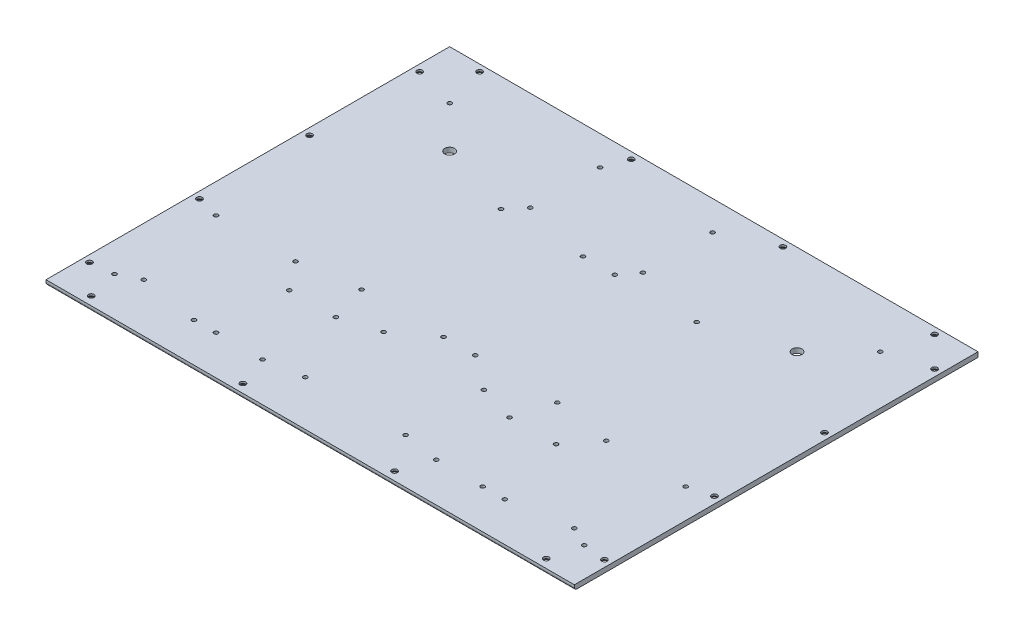
from build123d import *

# Parameters (mm, degrees)
SKETCH_2_W                   = 432
SKETCH_2_H                   = 330
EXTRUDE_1_DEPTH              = 4
HOLE_WIZARD_406_AT_2_COUNT   = 2
HOLE_WIZARD_406_AT_2_PITCH   = 294.02253315
HOLE_WIZARD_406_AT_3_COUNT   = 2
HOLE_WIZARD_406_AT_3_PITCH   = 204.473103366
HOLE_WIZARD_406_AT_4_COUNT   = 2
HOLE_WIZARD_406_AT_4_PITCH   = 115.625472972
HOLE_WIZARD_406_AT_5_COUNT   = 2
HOLE_WIZARD_406_AT_5_PITCH   = 33.604315199
HOLE_WIZARD_406_AT_6_COUNT   = 2
HOLE_WIZARD_406_AT_6_PITCH   = 124
HOLE_WIZARD_406_AT_7_COUNT   = 2
HOLE_WIZARD_406_AT_7_PITCH   = 248
HOLE_WIZARD_406_AT_8_COUNT   = 2
HOLE_WIZARD_406_AT_8_PITCH   = 372
HOLE_WIZARD_406_AT_9_COUNT   = 2
HOLE_WIZARD_406_AT_9_PITCH   = 397.166526787
HOLE_WIZARD_406_AT_10_COUNT  = 2
HOLE_WIZARD_406_AT_10_PITCH  = 412.28782422
HOLE_WIZARD_406_AT_11_COUNT  = 2
HOLE_WIZARD_406_AT_11_PITCH  = 445.445002217
HOLE_WIZARD_406_AT_12_COUNT  = 2
HOLE_WIZARD_406_AT_12_PITCH  = 493.012423779
HOLE_WIZARD_406_AT_13_COUNT  = 2
HOLE_WIZARD_406_AT_13_PITCH  = 489.070802645
HOLE_WIZARD_406_AT_14_COUNT  = 2
HOLE_WIZARD_406_AT_14_PITCH  = 402.87746276
HOLE_WIZARD_406_AT_15_COUNT  = 2
HOLE_WIZARD_406_AT_15_PITCH  = 340.855174524
HOLE_WIZARD_406_AT_16_COUNT  = 2
HOLE_WIZARD_406_AT_16_PITCH  = 317.5
FILLET_1_R                   = 2
HOLE_WIZARD_1584_D           = 8
M4P8_D                       = 3.3
HOLE_WIZARD_3528_D           = 3.3
HOLE_WIZARD_3528_CSINK_D     = 4.05
HOLE_WIZARD_3528_CSINK_ANGLE = 90
M4P9_D                       = 3.3
M4P10_D                      = 3.3


with BuildPart() as part:
    # 草圖2 → 填料-伸長1 (new body)
    with BuildSketch(Plane(origin=(0, 0, 0), x_dir=(1, 0, 0), z_dir=(0, 1, 0))):
        with Locations((216, 165)):
            Rectangle(SKETCH_2_W, SKETCH_2_H)
    extrude(amount=EXTRUDE_1_DEPTH)

    # 草圖3 → Hole Wizard 406 (revolve, cut)
    with BuildSketch(Plane(origin=(30, 0, -7), x_dir=(0, 0, -1), z_dir=(1, 0, 0))):
        Polygon((0, 0), (0, 4), (2.25, 4), (2.25, 2.45), (4.7, 0), align=None)
    hole_wizard_406 = revolve(axis=Axis((30, -6.35, -7), (0, 1, 0)), mode=Mode.SUBTRACT)

    # Hole Wizard 406 at 2: Hole Wizard 406 ×2
    with Locations(*[Vector(-0.083326947, 0, -0.996522263) * (i * HOLE_WIZARD_406_AT_2_PITCH) for i in range(1, HOLE_WIZARD_406_AT_2_COUNT)]):
        add(hole_wizard_406, mode=Mode.SUBTRACT)

    # Hole Wizard 406 at 3: Hole Wizard 406 ×2
    with Locations(*[Vector(-0.11982016, 0, -0.992795613) * (i * HOLE_WIZARD_406_AT_3_PITCH) for i in range(1, HOLE_WIZARD_406_AT_3_COUNT)]):
        add(hole_wizard_406, mode=Mode.SUBTRACT)

    # Hole Wizard 406 at 4: Hole Wizard 406 ×2
    with Locations(*[Vector(-0.211891025, 0, -0.9772933) * (i * HOLE_WIZARD_406_AT_4_PITCH) for i in range(1, HOLE_WIZARD_406_AT_4_COUNT)]):
        add(hole_wizard_406, mode=Mode.SUBTRACT)

    # Hole Wizard 406 at 5: Hole Wizard 406 ×2
    with Locations(*[Vector(-0.729073033, 0, -0.684435908) * (i * HOLE_WIZARD_406_AT_5_PITCH) for i in range(1, HOLE_WIZARD_406_AT_5_COUNT)]):
        add(hole_wizard_406, mode=Mode.SUBTRACT)

    # Hole Wizard 406 at 6: Hole Wizard 406 ×2
    with Locations(*[(i * HOLE_WIZARD_406_AT_6_PITCH, 0, 0) for i in range(1, HOLE_WIZARD_406_AT_6_COUNT)]):
        add(hole_wizard_406, mode=Mode.SUBTRACT)

    # Hole Wizard 406 at 7: Hole Wizard 406 ×2
    with Locations(*[(i * HOLE_WIZARD_406_AT_7_PITCH, 0, 0) for i in range(1, HOLE_WIZARD_406_AT_7_COUNT)]):
        add(hole_wizard_406, mode=Mode.SUBTRACT)

    # Hole Wizard 406 at 8: Hole Wizard 406 ×2
    with Locations(*[(i * HOLE_WIZARD_406_AT_8_PITCH, 0, 0) for i in range(1, HOLE_WIZARD_406_AT_8_COUNT)]):
        add(hole_wizard_406, mode=Mode.SUBTRACT)

    # Hole Wizard 406 at 9: Hole Wizard 406 ×2
    with Locations(*[Vector(0.998321795, 0, -0.057910218) * (i * HOLE_WIZARD_406_AT_9_PITCH) for i in range(1, HOLE_WIZARD_406_AT_9_COUNT)]):
        add(hole_wizard_406, mode=Mode.SUBTRACT)

    # Hole Wizard 406 at 10: Hole Wizard 406 ×2
    with Locations(*[Vector(0.96170679, 0, -0.274080371) * (i * HOLE_WIZARD_406_AT_10_PITCH) for i in range(1, HOLE_WIZARD_406_AT_10_COUNT)]):
        add(hole_wizard_406, mode=Mode.SUBTRACT)

    # Hole Wizard 406 at 11: Hole Wizard 406 ×2
    with Locations(*[Vector(0.89012111, 0, -0.455724049) * (i * HOLE_WIZARD_406_AT_11_PITCH) for i in range(1, HOLE_WIZARD_406_AT_11_COUNT)]):
        add(hole_wizard_406, mode=Mode.SUBTRACT)

    # Hole Wizard 406 at 12: Hole Wizard 406 ×2
    with Locations(*[Vector(0.804239368, 0, -0.59430551) * (i * HOLE_WIZARD_406_AT_12_PITCH) for i in range(1, HOLE_WIZARD_406_AT_12_COUNT)]):
        add(hole_wizard_406, mode=Mode.SUBTRACT)

    # Hole Wizard 406 at 13: Hole Wizard 406 ×2
    with Locations(*[Vector(0.760626065, 0, -0.649190257) * (i * HOLE_WIZARD_406_AT_13_PITCH) for i in range(1, HOLE_WIZARD_406_AT_13_COUNT)]):
        add(hole_wizard_406, mode=Mode.SUBTRACT)

    # Hole Wizard 406 at 14: Hole Wizard 406 ×2
    with Locations(*[Vector(0.615571788, 0, -0.788080817) * (i * HOLE_WIZARD_406_AT_14_PITCH) for i in range(1, HOLE_WIZARD_406_AT_14_COUNT)]):
        add(hole_wizard_406, mode=Mode.SUBTRACT)

    # Hole Wizard 406 at 15: Hole Wizard 406 ×2
    with Locations(*[Vector(0.363790869, 0, -0.931480651) * (i * HOLE_WIZARD_406_AT_15_PITCH) for i in range(1, HOLE_WIZARD_406_AT_15_COUNT)]):
        add(hole_wizard_406, mode=Mode.SUBTRACT)

    # Hole Wizard 406 at 16: Hole Wizard 406 ×2
    with Locations(*[(0, 0, -i * HOLE_WIZARD_406_AT_16_PITCH) for i in range(1, HOLE_WIZARD_406_AT_16_COUNT)]):
        add(hole_wizard_406, mode=Mode.SUBTRACT)

    # 圓角1
    fillet_1_edges = [part.edges().sort_by_distance(p)[0] for p in [
        (216, 0, 0),
    ]]
    fillet(fillet_1_edges, radius=FILLET_1_R)

    # Hole Wizard 1584 (through all)
    with Locations(Plane(origin=(0, 0, 0), x_dir=(-1, 0, 0), z_dir=(0, -1, 0))):
        with Locations((-74, 256), (-358, 256)):
            Hole(HOLE_WIZARD_1584_D / 2)

    # M4P8 (through all)
    with Locations(Plane(origin=(0, 0, 0), x_dir=(-1, 0, 0), z_dir=(0, -1, 0))):
        with Locations((-107, 32), (-107, 92), (-145, 32), (-145, 92), (-287, 32), (-287, 92), (-325, 32), (-325, 92), (-147, 249), (-239, 249), (-147, 306), (-239, 306)):
            Hole(M4P8_D / 2)

    # Hole Wizard 3528 (through all)
    with Locations(Plane(origin=(0, 0, 0), x_dir=(-1, 0, 0), z_dir=(0, -1, 0))):
        with Locations((-40, 40), (-40, 290), (-392, 290), (-392, 40)):
            CounterSinkHole(HOLE_WIZARD_3528_D / 2, HOLE_WIZARD_3528_CSINK_D / 2, counter_sink_angle=HOLE_WIZARD_3528_CSINK_ANGLE)

    # M4P9 (through all)
    with Locations(Plane(origin=(0, 0, 0), x_dir=(-1, 0, 0), z_dir=(0, -1, 0))):
        with Locations((-24, 32), (-89, 32), (-24, 115), (-89, 115), (-136, 122), (-136, 236), (-203, 122), (-203, 236), (-229, 122), (-229, 236), (-296, 122), (-296, 236), (-343, 32), (-408, 32), (-408, 115), (-343, 115)):
            Hole(M4P9_D / 2)

    # M4P10 (through all)
    with Locations(Plane(origin=(0, 0, 0), x_dir=(-1, 0, 0), z_dir=(0, -1, 0))):
        with Locations((-175, 37), (-257, 37), (-257, 101), (-175, 101)):
            Hole(M4P10_D / 2)


solid = part.part
